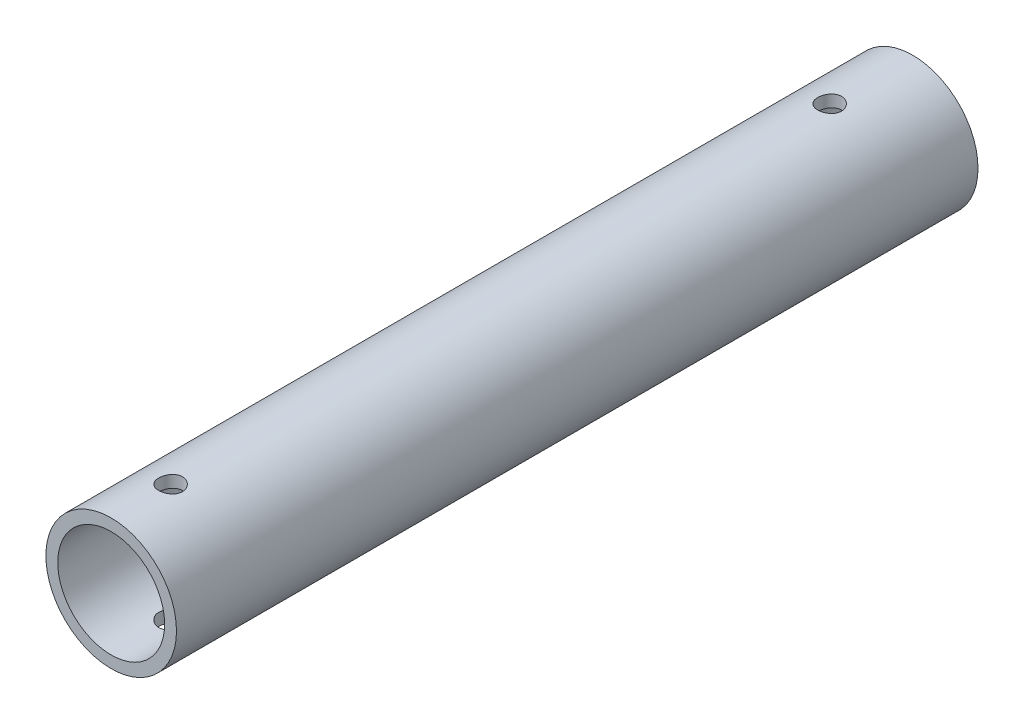
from build123d import *

# Parameters (mm, degrees)
SKETCH1_R                  = 5.5
SKETCH1_R_2                = 4.5
BOSS_EXTRUDE1_DEPTH        = 67.5
IZIM2_R                    = 1
KES_EKSTR_ZYON1_DEPTH      = 6.5
KES_EKSTR_ZYON1_DEPTH_BACK = 6.5
IZIM3_R                    = 1
KES_EKSTR_ZYON2_DEPTH      = 6.500000118
KES_EKSTR_ZYON2_DEPTH_BACK = 6.500000118


with BuildPart() as part:
    # Sketch1 → Boss-Extrude1 (new body)
    with BuildSketch(Plane.XY):
        Circle(SKETCH1_R)
        Circle(SKETCH1_R_2, mode=Mode.SUBTRACT)
    extrude(amount=BOSS_EXTRUDE1_DEPTH)

    # Çizim2 → Kes-Ekstrüzyon1 (cut, two sides)
    with BuildSketch(Plane(origin=(0, 0, 0), x_dir=(1, 0, 0), z_dir=(0, 1, 0))) as kes_ekstr_zyon1_sk:
        with Locations((0, -7)):
            Circle(IZIM2_R)
    extrude(amount=KES_EKSTR_ZYON1_DEPTH, mode=Mode.SUBTRACT)
    extrude(kes_ekstr_zyon1_sk.sketch, amount=-KES_EKSTR_ZYON1_DEPTH_BACK, mode=Mode.SUBTRACT)

    # Çizim3 → Kes-Ekstrüzyon2 (cut, two sides)
    with BuildSketch(Plane(origin=(0, 0, 0), x_dir=(1, 0, 0), z_dir=(0, 1, 0))) as kes_ekstr_zyon2_sk:
        with Locations((0, -62.5)):
            Circle(IZIM3_R)
    extrude(amount=KES_EKSTR_ZYON2_DEPTH, mode=Mode.SUBTRACT)
    extrude(kes_ekstr_zyon2_sk.sketch, amount=-KES_EKSTR_ZYON2_DEPTH_BACK, mode=Mode.SUBTRACT)


solid = part.part
